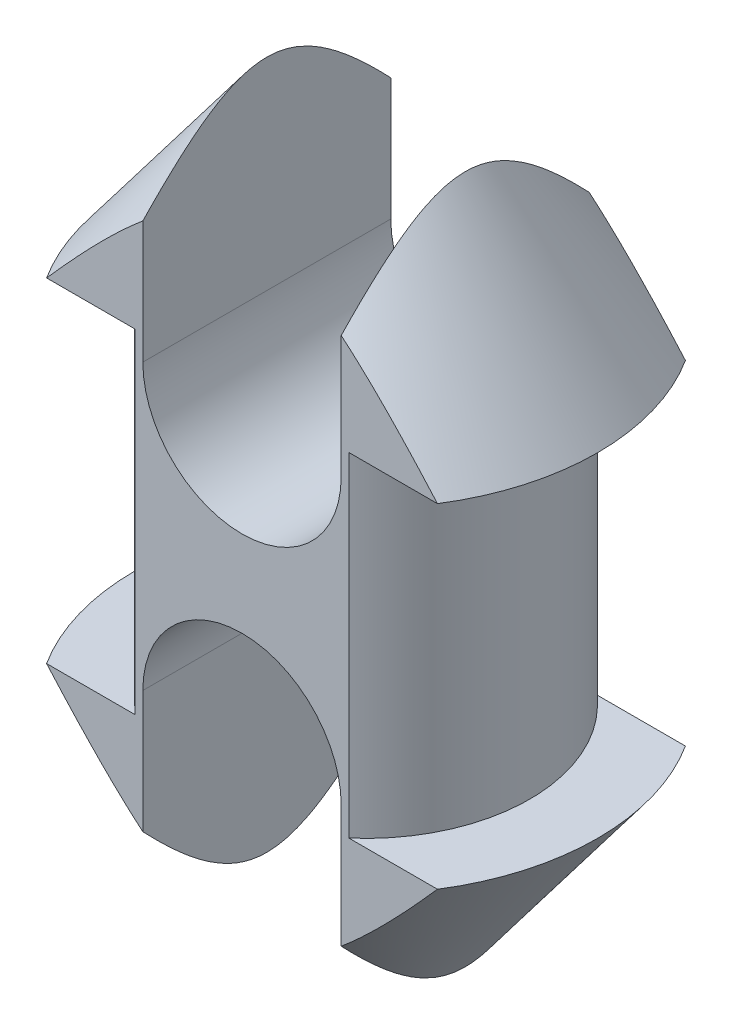
from build123d import *

# Parameters (mm, degrees)
ESBO_O2_OUTSIDE_W          = 42.476
ESBO_O2_OUTSIDE_H          = 42.476
ESBO_O2_OUTSIDE_W_2        = 28
ESBO_O2_OUTSIDE_H_2        = 15
CORTE_EXTRUS_O1_DEPTH      = 25.1
CORTE_EXTRUS_O1_DEPTH_BACK = 25.1
CORTE_EXTRUS_O2_DEPTH      = 16


with BuildPart() as part:
    # Esboço1 one side → Revolução1 (revolve)
    with BuildSketch(Plane.XY):
        with BuildLine():
            ThreePointArc((4, 23.516407865), (2.02117415, 23.953333716), (0, 24.1))
            Line((0, 24.1), (0, -24.1))
            ThreePointArc((0, -24.1), (2.02117415, -23.953333716), (4, -23.516407865))
            Line((4, -23.516407865), (14, -10.1))
            Line((14, -10.1), (9.9, -10.1))
            Line((9.9, -10.1), (9.9, 10.1))
            Line((9.9, 10.1), (14, 10.1))
            Line((14, 10.1), (4, 23.516407865))
        make_face()
    revolve(axis=Axis((0, -24.1, 0), (0, 1, 0)))

    # Esboço2 outside → Corte-extrusão1 (cut, two sides)
    with BuildSketch(Plane(origin=(0, 0, 0), x_dir=(1, 0, 0), z_dir=(0, 1, 0))) as corte_extrus_o1_sk:
        Rectangle(ESBO_O2_OUTSIDE_W, ESBO_O2_OUTSIDE_H)
        Rectangle(ESBO_O2_OUTSIDE_W_2, ESBO_O2_OUTSIDE_H_2, mode=Mode.SUBTRACT)
    extrude(amount=CORTE_EXTRUS_O1_DEPTH, mode=Mode.SUBTRACT)
    extrude(corte_extrus_o1_sk.sketch, amount=-CORTE_EXTRUS_O1_DEPTH_BACK, mode=Mode.SUBTRACT)

    # Esboço3 → Corte-extrusão2 (cut, through all)
    with BuildSketch(Plane(origin=(0, 0, -7.5), x_dir=(-1, 0, 0), z_dir=(0, 0, -1))):
        with BuildLine():
            Line((6, 24.1), (6, 8.6))
            ThreePointArc((6, 8.6), (0, 2.6), (-6, 8.6))
            Line((-6, 8.6), (-6, 24.1))
            ThreePointArc((-6, 24.1), (0, 30.1), (6, 24.1))
        make_face()
        with BuildLine():
            Line((-6, -24.1), (-6, -8.6))
            ThreePointArc((-6, -8.6), (0, -2.6), (6, -8.6))
            Line((6, -8.6), (6, -24.1))
            ThreePointArc((6, -24.1), (0, -30.1), (-6, -24.1))
        make_face()
    extrude(amount=-CORTE_EXTRUS_O2_DEPTH, mode=Mode.SUBTRACT)


solid = part.part
